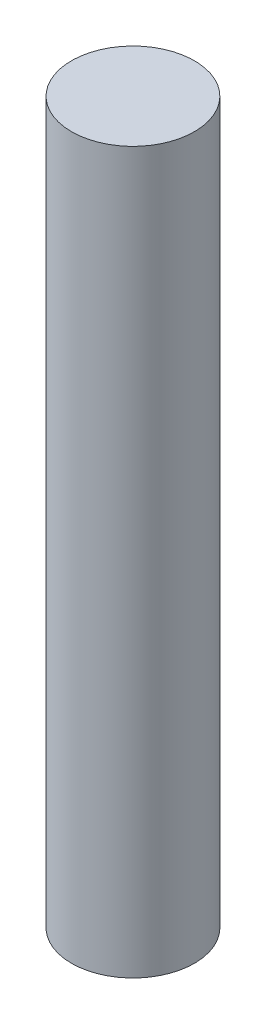
from build123d import *

# Parameters (mm, degrees)
SKETCH1_R           = 7.9375
BOSS_EXTRUDE1_DEPTH = 93


with BuildPart() as part:
    # Sketch1 → Boss-Extrude1 (new body)
    with BuildSketch(Plane(origin=(0, 0, 0), x_dir=(1, 0, 0), z_dir=(0, 1, 0))):
        Circle(SKETCH1_R)
    extrude(amount=BOSS_EXTRUDE1_DEPTH)


solid = part.part
